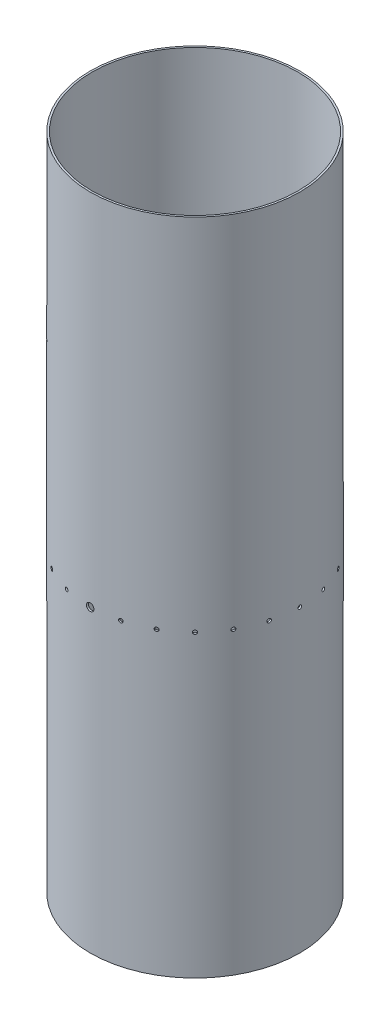
from build123d import *

# Parameters (mm, degrees)
SKETCH1_R               = 88.9
SKETCH1_R_2             = 87.3125
BOSS_EXTRUDE1_DEPTH     = 558.8
SKETCH10_R              = 1.5875
CUT_EXTRUDE1_DEPTH      = 3.81
CIRPATTERN1_COUNT       = 24
CUT_EXTRUDE2_DEPTH      = 594.104957126
CUT_EXTRUDE2_DEPTH_BACK = 594.104957126
SKETCH12_R              = 3.175
CUT_EXTRUDE5_DEPTH      = 573.768592145
CUT_EXTRUDE5_DEPTH_BACK = 573.768592145
SKETCH16_R              = 2.0955


with BuildPart() as part:
    # Sketch1 → Boss-Extrude1 (new body)
    with BuildSketch(Plane(origin=(0, 0, 0), x_dir=(1, 0, 0), z_dir=(0, 1, 0))):
        Circle(SKETCH1_R)
        Circle(SKETCH1_R_2, mode=Mode.SUBTRACT)
    extrude(amount=BOSS_EXTRUDE1_DEPTH)

    # Sketch10 → Cut-Extrude1 (cut)
    with BuildSketch(Plane.XY.offset(88.9)):
        with Locations((0, 254)):
            Circle(SKETCH10_R)
    cut_extrude1 = extrude(amount=-CUT_EXTRUDE1_DEPTH, mode=Mode.SUBTRACT)

    # CirPattern1: Cut-Extrude1 ×24 about axis
    cirpattern1_axis = Axis((0, 558.8, 0), (0, -1, 0))
    for i in range(1, CIRPATTERN1_COUNT):
        add(cut_extrude1.rotate(cirpattern1_axis, i * 360 / CIRPATTERN1_COUNT), mode=Mode.SUBTRACT)

    # Sketch12 → Cut-Extrude2 (cut, two sides: drawn at the far end of the back side and taken through both)
    with BuildSketch(Plane.XY.offset(88.9).offset(-CUT_EXTRUDE2_DEPTH_BACK)):
        with Locations((0, 254)):
            Circle(SKETCH12_R)
    extrude(amount=CUT_EXTRUDE2_DEPTH + CUT_EXTRUDE2_DEPTH_BACK, mode=Mode.SUBTRACT)

    # Sketch16 → Cut-Extrude5 (cut, two sides: drawn at the far end of the back side and taken through both)
    with BuildSketch(Plane.XY.offset(-CUT_EXTRUDE5_DEPTH_BACK)):
        with Locations((-63.5, 406.4)):
            Circle(SKETCH16_R)
    extrude(amount=CUT_EXTRUDE5_DEPTH + CUT_EXTRUDE5_DEPTH_BACK, mode=Mode.SUBTRACT)


solid = part.part
